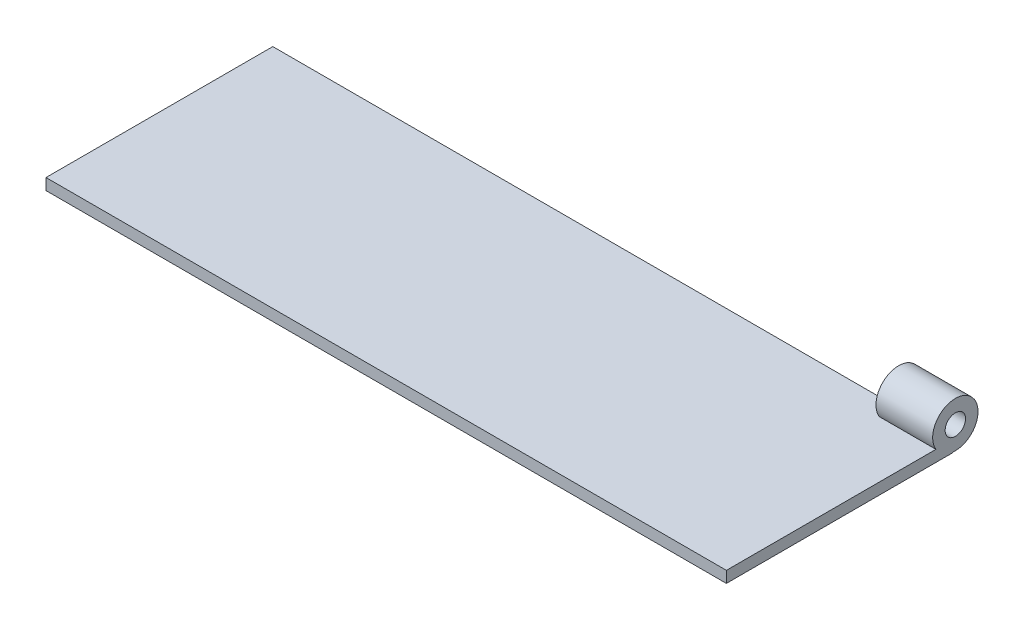
from build123d import *

# Parameters (mm, degrees)
SKETCH1_W           = 300
SKETCH1_H           = 100
BOSS_EXTRUDE1_DEPTH = 5
SKETCH7_R           = 10
BOSS_EXTRUDE5_DEPTH = 25
SKETCH10_R          = 4.5
CUT_EXTRUDE1_DEPTH  = 25


with BuildPart() as part:
    # Sketch1 → Boss-Extrude1 (new body)
    with BuildSketch(Plane(origin=(0, 0, 0), x_dir=(1, 0, 0), z_dir=(0, 1, 0))):
        Rectangle(SKETCH1_W, SKETCH1_H)
    extrude(amount=BOSS_EXTRUDE1_DEPTH)

    # Sketch7 → Boss-Extrude5 (add)
    with BuildSketch(Plane(origin=(150, 0, 0), x_dir=(0, 0, -1), z_dir=(1, 0, 0))):
        with Locations((50.954154719, 10.172311349)):
            Circle(SKETCH7_R)
    extrude(amount=-BOSS_EXTRUDE5_DEPTH)

    # Sketch10 → Cut-Extrude1 (cut)
    with BuildSketch(Plane(origin=(150, 0, 0), x_dir=(0, 0, -1), z_dir=(1, 0, 0))):
        with Locations((50.954154719, 10.172311349)):
            Circle(SKETCH10_R)
    extrude(amount=-CUT_EXTRUDE1_DEPTH, mode=Mode.SUBTRACT)


solid = part.part
